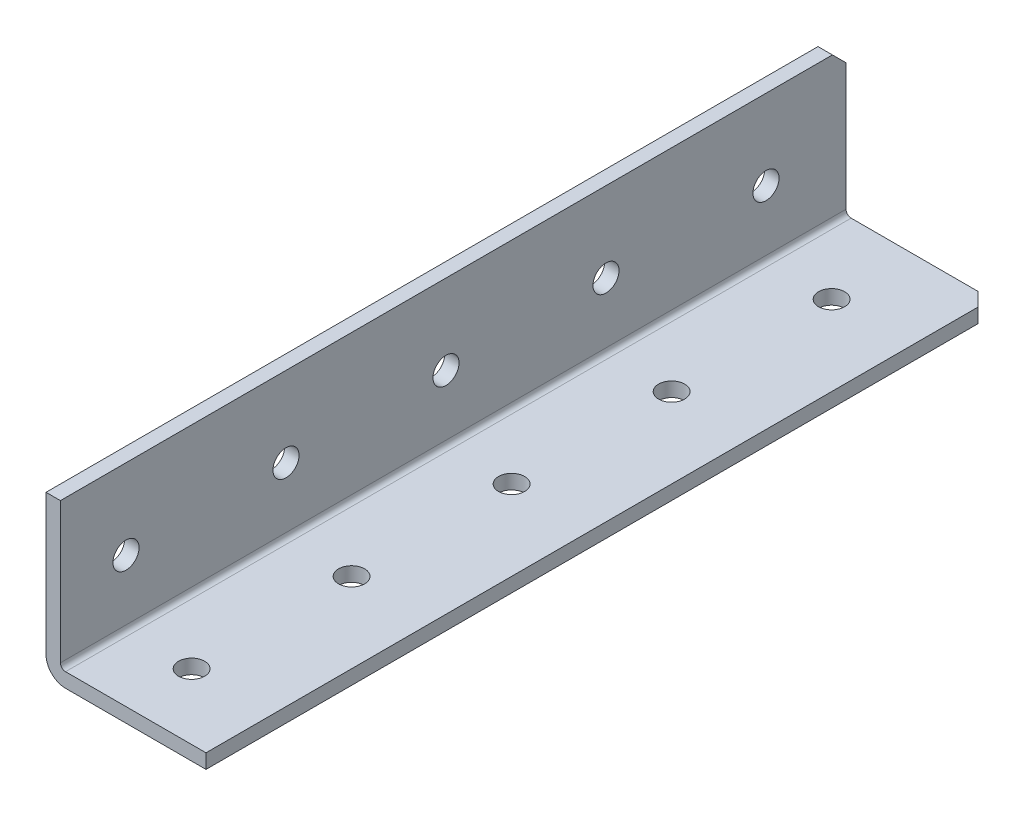
from build123d import *

# Parameters (mm, degrees)
SKETCH1_W                  = 25.4
SKETCH1_H                  = 1498.6
BOSS_EXTRUDE1_DEPTH        = 25.4
SKETCH2_W                  = 23.114
SKETCH2_H                  = 23.114
CUT_EXTRUDE1_DEPTH         = 1499.6
M3_5_CLEARANCE_HOLE1_D     = 4.1402
M3_5_CLEARANCE_HOLE1_DEPTH = 25.4
M3_5_CLEARANCE_HOLE2_D     = 4.1402
M3_5_CLEARANCE_HOLE2_DEPTH = 25.4
CHAMFER1_SIZE              = 2.159
FILLET1_R                  = 0.8128
FILLET2_R                  = 3.0988
SKETCH8_W                  = 95.882963774
SKETCH8_H                  = 79.338329604
CUT_EXTRUDE3_DEPTH         = 1371.6
SKETCH11_W                 = 51.462522779
SKETCH11_H                 = 66.676735099
CUT_EXTRUDE6_DEPTH         = 2.286


with BuildPart() as part:
    # Sketch1 → Boss-Extrude1 (new body)
    with BuildSketch(Plane(origin=(0, 0, 0), x_dir=(0, -1, 0), z_dir=(-1, 0, 0))):
        with Locations((-12.7, 0)):
            Rectangle(SKETCH1_W, SKETCH1_H)
    extrude(amount=-BOSS_EXTRUDE1_DEPTH)

    # Sketch2 → Cut-Extrude1 (cut, through all)
    with BuildSketch(Plane(origin=(0, 0, -749.3), x_dir=(-1, 0, 0), z_dir=(0, 0, -1))):
        with Locations((-13.843, 13.843)):
            Rectangle(SKETCH2_W, SKETCH2_H)
    extrude(amount=-CUT_EXTRUDE1_DEPTH, mode=Mode.SUBTRACT)

    # M3.5 Clearance Hole1
    with Locations(Plane(origin=(0, 0, 0), x_dir=(-1, 0, 0), z_dir=(0, -1, 0))):
        with Locations((-12.7, 736.6), (-12.7, 711.2), (-12.7, 685.8), (-12.7, 660.4), (-12.7, 635), (-12.7, 609.6), (-12.7, 584.2), (-12.7, 558.8), (-12.7, 533.4), (-12.7, 508), (-12.7, 482.6), (-12.7, 457.2), (-12.7, 431.8), (-12.7, 406.4), (-12.7, 381), (-12.7, 355.6), (-12.7, 330.2), (-12.7, 304.8), (-12.7, 279.4), (-12.7, 254), (-12.7, 228.6), (-12.7, 203.2), (-12.7, 177.8), (-12.7, 152.4), (-12.7, 127), (-12.7, 101.6), (-12.7, 76.2), (-12.7, 50.8), (-12.7, 25.4), (-12.7, 0), (-12.7, -25.4), (-12.7, -50.8), (-12.7, -76.2), (-12.7, -101.6), (-12.7, -127), (-12.7, -152.4), (-12.7, -177.8), (-12.7, -203.2), (-12.7, -228.6), (-12.7, -254), (-12.7, -279.4), (-12.7, -304.8), (-12.7, -330.2), (-12.7, -355.6), (-12.7, -381), (-12.7, -406.4), (-12.7, -431.8), (-12.7, -457.2), (-12.7, -482.6), (-12.7, -508), (-12.7, -533.4), (-12.7, -558.8), (-12.7, -584.2), (-12.7, -609.6), (-12.7, -635), (-12.7, -660.4), (-12.7, -685.8), (-12.7, -711.2), (-12.7, -736.6)):
            Hole(M3_5_CLEARANCE_HOLE1_D / 2, depth=M3_5_CLEARANCE_HOLE1_DEPTH)

    # M3.5 Clearance Hole2
    with Locations(Plane.ZY):
        with Locations((711.2, 12.7), (736.6, 12.7), (685.8, 12.7), (660.4, 12.7), (635, 12.7), (609.6, 12.7), (584.2, 12.7), (558.8, 12.7), (533.4, 12.7), (508, 12.7), (482.6, 12.7), (457.2, 12.7), (431.8, 12.7), (406.4, 12.7), (381, 12.7), (355.6, 12.7), (330.2, 12.7), (304.8, 12.7), (279.4, 12.7), (254, 12.7), (228.6, 12.7), (203.2, 12.7), (177.8, 12.7), (152.4, 12.7), (127, 12.7), (101.6, 12.7), (76.2, 12.7), (50.8, 12.7), (25.4, 12.7), (0, 12.7), (-25.4, 12.7), (-50.8, 12.7), (-76.2, 12.7), (-101.6, 12.7), (-127, 12.7), (-152.4, 12.7), (-177.8, 12.7), (-203.2, 12.7), (-228.6, 12.7), (-254, 12.7), (-279.4, 12.7), (-304.8, 12.7), (-330.2, 12.7), (-355.6, 12.7), (-381, 12.7), (-406.4, 12.7), (-431.8, 12.7), (-457.2, 12.7), (-482.6, 12.7), (-508, 12.7), (-533.4, 12.7), (-558.8, 12.7), (-584.2, 12.7), (-609.6, 12.7), (-635, 12.7), (-660.4, 12.7), (-685.8, 12.7), (-711.2, 12.7), (-736.6, 12.7)):
            Hole(M3_5_CLEARANCE_HOLE2_D / 2, depth=M3_5_CLEARANCE_HOLE2_DEPTH)

    # Chamfer1
    chamfer1_edges = [part.edges().sort_by_distance(p)[0] for p in [
        (25.4, 1.143, -749.3),
        (1.143, 25.4, 749.3),
        (1.143, 25.4, -749.3),
        (25.4, 1.143, 749.3),
    ]]
    chamfer(chamfer1_edges, length=CHAMFER1_SIZE)

    # Fillet1
    fillet1_edges = [part.edges().sort_by_distance(p)[0] for p in [
        (2.286, 2.286, 0),
    ]]
    fillet(fillet1_edges, radius=FILLET1_R)

    # Fillet2
    fillet2_edges = [part.edges().sort_by_distance(p)[0] for p in [
        (0, 0, 0),
    ]]
    fillet(fillet2_edges, radius=FILLET2_R)

    # Sketch8 → Cut-Extrude3 (cut)
    with BuildSketch(Plane.XY.offset(749.3)):
        with Locations((2.286, 3.0988)):
            Rectangle(SKETCH8_W, SKETCH8_H)
    extrude(amount=-CUT_EXTRUDE3_DEPTH, mode=Mode.SUBTRACT)

    # Sketch11 → Cut-Extrude6 (cut)
    with BuildSketch(Plane.XY.offset(-622.3)):
        with Locations((1.85517497, 1.74884985)):
            Rectangle(SKETCH11_W, SKETCH11_H)
    extrude(amount=-CUT_EXTRUDE6_DEPTH, mode=Mode.SUBTRACT)


solid = part.part
